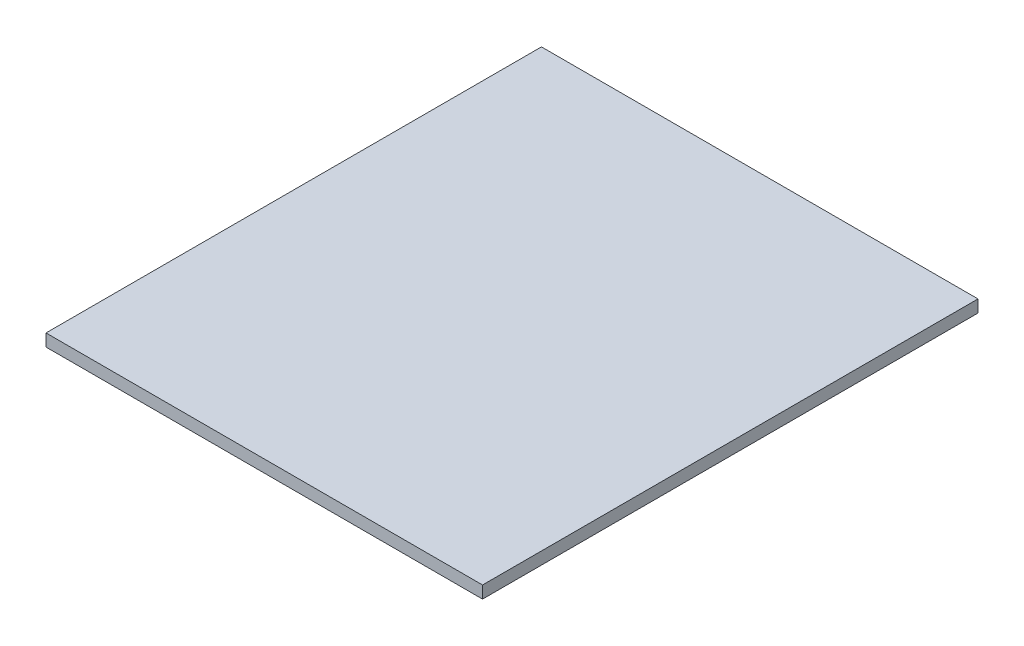
from build123d import *

# Parameters (mm, degrees)
SKETCH1_W           = 2260.346
SKETCH1_H           = 2565.4
BOSS_EXTRUDE1_DEPTH = 63.5


with BuildPart() as part:
    # Sketch1 → Boss-Extrude1 (new body)
    with BuildSketch(Plane(origin=(0, 0, 0), x_dir=(1, 0, 0), z_dir=(0, 1, 0))):
        Rectangle(SKETCH1_W, SKETCH1_H)
    extrude(amount=BOSS_EXTRUDE1_DEPTH)


solid = part.part
